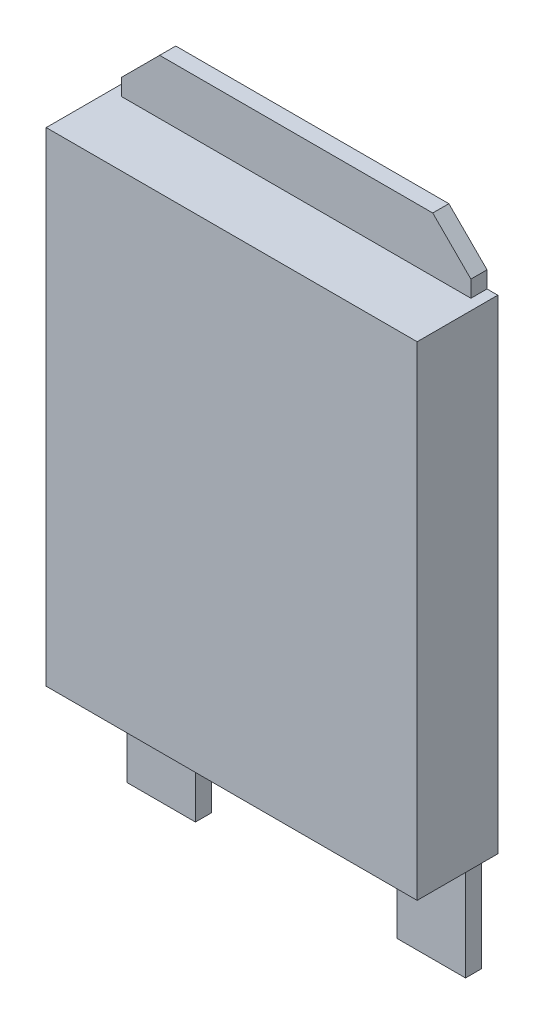
from build123d import *

# Parameters (mm, degrees)
SKETCH1_W           = 6.9
SKETCH1_H           = 9
BOSS_EXTRUDE1_DEPTH = 1.5
SKETCH2_W           = 1.27616984
SKETCH2_H           = 2
BOSS_EXTRUDE2_DEPTH = 0.3


with BuildPart() as part:
    # Sketch1 → Boss-Extrude1 (new body)
    with BuildSketch(Plane.XY):
        Rectangle(SKETCH1_W, SKETCH1_H)
    extrude(amount=BOSS_EXTRUDE1_DEPTH)

    # Sketch2 → Boss-Extrude2 (add)
    with BuildSketch(Plane.XY):
        Polygon((3.25, 4.5), (3.25, 4.808852059), (2.54, 5.518852059), (-2.54, 5.518852059), (-3.25, 4.808852059), (-3.25, 4.5), align=None)
        with Locations((2.51191508, -5.5)):
            Rectangle(SKETCH2_W, SKETCH2_H)
        with Locations((-2.51191508, -5.5)):
            Rectangle(SKETCH2_W, SKETCH2_H)
    extrude(amount=BOSS_EXTRUDE2_DEPTH)


solid = part.part
